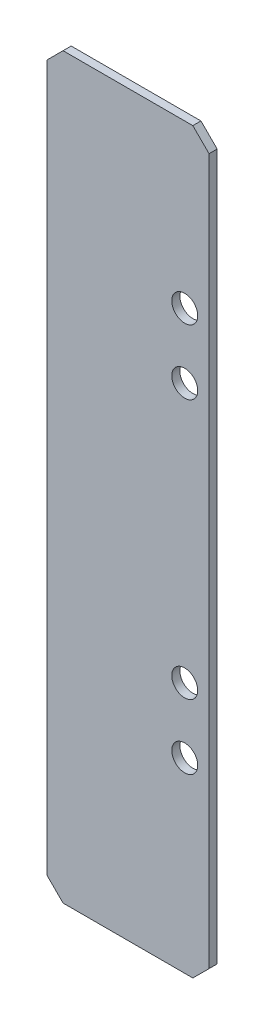
from build123d import *

# Parameters (mm, degrees)
SKETCH_1_W      = 20
SKETCH_1_H      = 91
SKETCH_1_R      = 1.6
EXTRUDE_1_DEPTH = 1
CHAMFER_1_SIZE  = 2


with BuildPart() as part:
    # 草图1 → 凸台-拉伸1 (new body)
    with BuildSketch(Plane.XY):
        Rectangle(SKETCH_1_W, SKETCH_1_H)
        with Locations((7, 25.5)):
            Circle(SKETCH_1_R, mode=Mode.SUBTRACT)
        with Locations((7, 17.5)):
            Circle(SKETCH_1_R, mode=Mode.SUBTRACT)
        with Locations((7, -14.5)):
            Circle(SKETCH_1_R, mode=Mode.SUBTRACT)
        with Locations((7, -22.5)):
            Circle(SKETCH_1_R, mode=Mode.SUBTRACT)
    extrude(amount=EXTRUDE_1_DEPTH)

    # 倒角1
    chamfer_1_edges = [part.edges().sort_by_distance(p)[0] for p in [
        (10, -45.5, 0.5),
        (-10, -45.5, 0.5),
        (-10, 45.5, 0.5),
        (10, 45.5, 0.5),
    ]]
    chamfer(chamfer_1_edges, length=CHAMFER_1_SIZE)


solid = part.part
